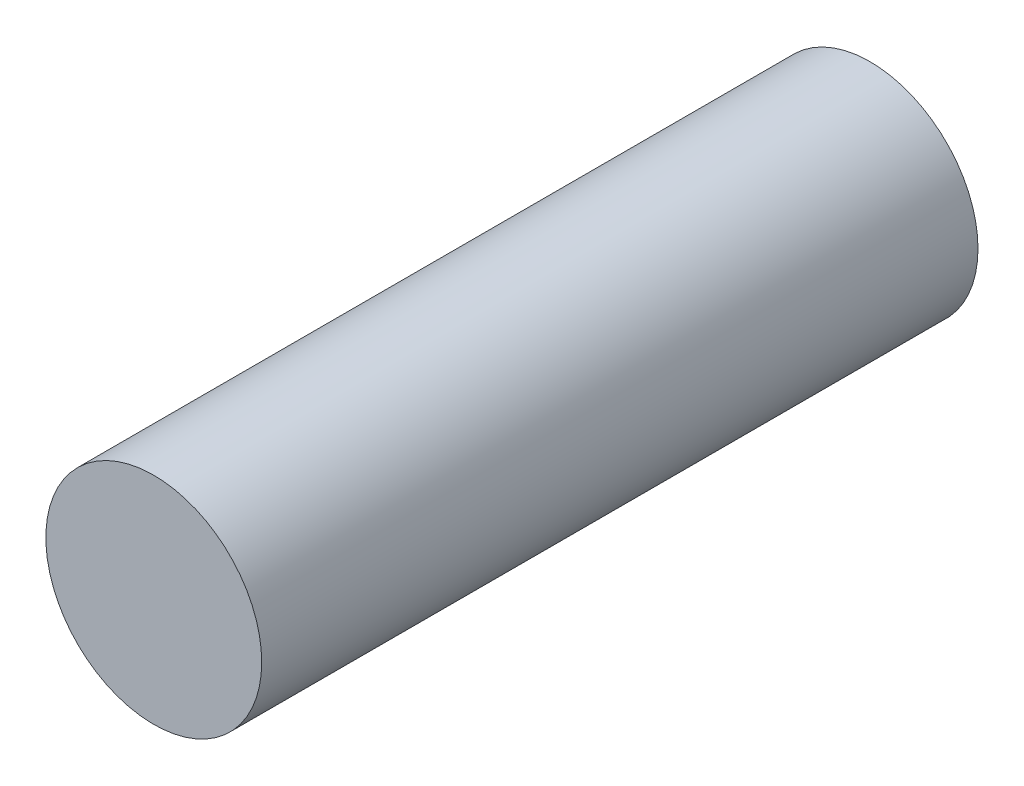
from build123d import *

# Parameters (mm, degrees)
IZIM1_R                     = 11
Y_KSEKLIK_EKSTR_ZYON1_DEPTH = 73


with BuildPart() as part:
    # Çizim1 → Yükseklik-Ekstrüzyon1 (new body)
    with BuildSketch(Plane(origin=(0, 0, 0), x_dir=(0, 1, 0), z_dir=(0, 0, 1))):
        Circle(IZIM1_R)
    extrude(amount=Y_KSEKLIK_EKSTR_ZYON1_DEPTH)


solid = part.part
